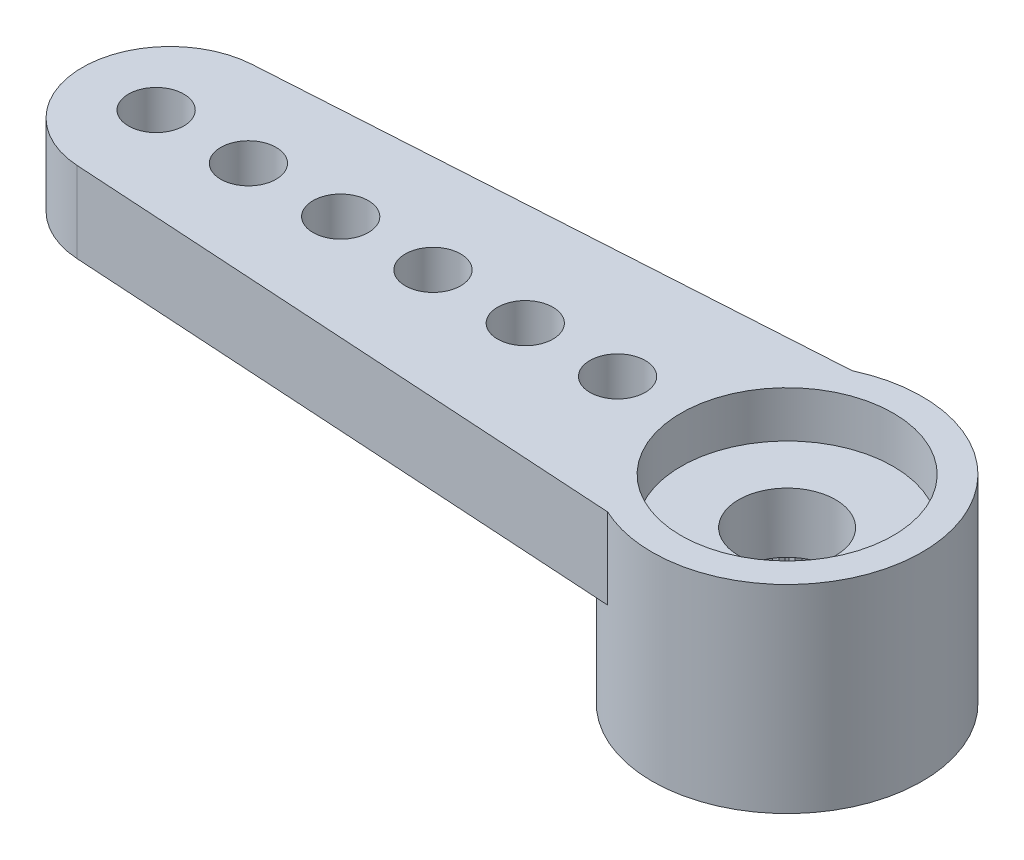
from build123d import *

# Parameters (mm, degrees)
RESSALTO_EXTRUS_O1_DEPTH = 1.75
ESBO_O2_R                = 2.925
RESSALTO_EXTRUS_O2_DEPTH = 2.55
FURO4_D                  = 1.2
PADR_O_LINEAR1_COUNT     = 6
PADR_O_LINEAR1_PITCH     = 2
FURO1_D                  = 4.95
FURO1_DEPTH              = 2
FURO2_D                  = 4.6
FURO2_DEPTH              = 1
FURO3_D                  = 2.1
RESSALTO_EXTRUS_O3_DEPTH = 2
PADR_OCIRCULAR1_COUNT    = 60


with BuildPart() as part:
    # Esboço1 → Ressalto-extrusão1 (new body)
    with BuildSketch(Plane(origin=(0, 0, 0), x_dir=(1, 0, 0), z_dir=(0, 1, 0))):
        with BuildLine():
            Line((-13.491629138, 1.896417054), (-1.23819425, 2.65))
            ThreePointArc((-1.23819425, 2.65), (2.925, 0), (-1.23819425, -2.65))
            Line((-1.23819425, -2.65), (-13.491629138, -1.896417054))
            ThreePointArc((-13.491629138, -1.896417054), (-15.275, 0), (-13.491629138, 1.896417054))
        make_face()
    extrude(amount=-RESSALTO_EXTRUS_O1_DEPTH)

    # Esboço2 → Ressalto-extrusão2 (add)
    with BuildSketch(Plane.XZ.offset(1.75)):
        Circle(ESBO_O2_R)
    extrude(amount=RESSALTO_EXTRUS_O2_DEPTH)

    # Furo4 (through all)
    with Locations(Plane(origin=(0, 0, 0), x_dir=(1, 0, 0), z_dir=(0, 1, 0))):
        with Locations((-13.675, 0)):
            furo4 = Hole(FURO4_D / 2)

    # Padrão linear1: Furo4 ×6
    with Locations(*[(i * PADR_O_LINEAR1_PITCH, 0, 0) for i in range(1, PADR_O_LINEAR1_COUNT)]):
        add(furo4, mode=Mode.SUBTRACT)

    # Furo1
    with Locations(Plane(origin=(0, -4.3, 0), x_dir=(-1, 0, 0), z_dir=(0, -1, 0))):
        with Locations((0, 0)):
            Hole(FURO1_D / 2, depth=FURO1_DEPTH)

    # Furo2
    with Locations(Plane(origin=(0, 0, 0), x_dir=(1, 0, 0), z_dir=(0, 1, 0))):
        with Locations((0, 0)):
            Hole(FURO2_D / 2, depth=FURO2_DEPTH)

    # Furo3 (through all)
    with Locations(Plane(origin=(0, 0, 0), x_dir=(1, 0, 0), z_dir=(0, 1, 0))):
        with Locations((0, 0)):
            Hole(FURO3_D / 2)

    # Esboço11 → Ressalto-extrusão3 (add)
    with BuildSketch(Plane.XZ.offset(4.3)):
        with BuildLine():
            Line((-0.098056786, 2.473056786), (0, 2.375))
            Line((0, 2.375), (0.098056786, 2.473056786))
            ThreePointArc((0.098056786, 2.473056786), (0, 2.475), (-0.098056786, 2.473056786))
        make_face()
    ressalto_extrus_o3 = extrude(amount=-RESSALTO_EXTRUS_O3_DEPTH)

    # PadrãoCircular1: Ressalto-extrusão3 ×60 about axis
    padr_ocircular1_axis = Axis((0, 0, 0), (0, 1, 0))
    for i in range(1, PADR_OCIRCULAR1_COUNT):
        add(ressalto_extrus_o3.rotate(padr_ocircular1_axis, i * 360 / PADR_OCIRCULAR1_COUNT))


solid = part.part
